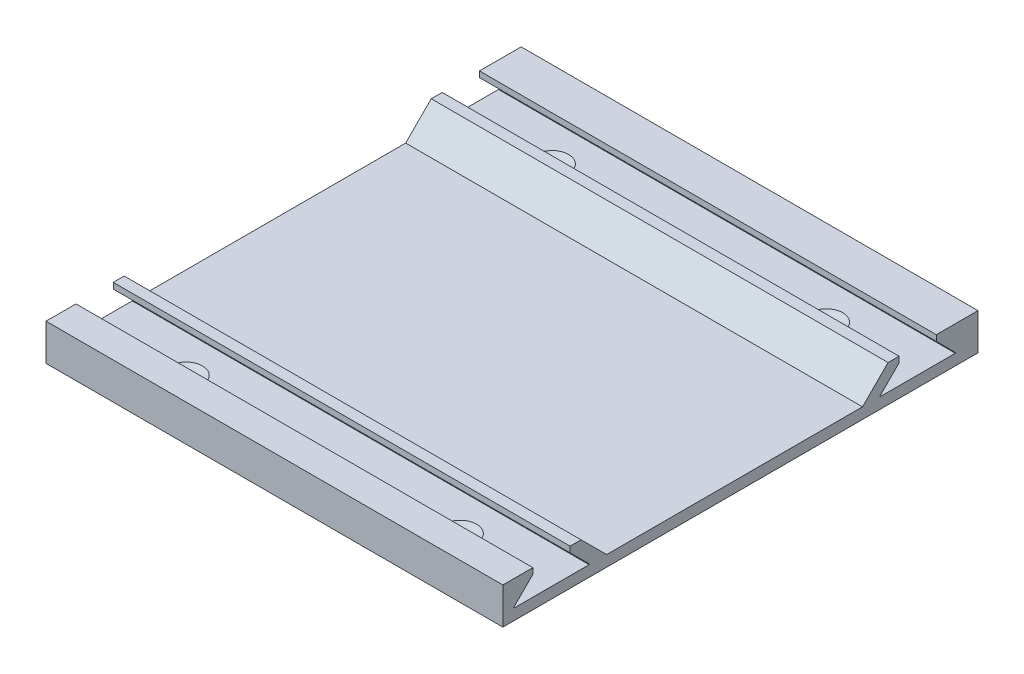
from build123d import *

# Parameters (mm, degrees)
ESQUISSE1_W             = 125
ESQUISSE1_H             = 130
BOSS_EXTRU_1_DEPTH      = 10
ENL_V_MAT_EXTRU_1_DEPTH = 125
ESQUISSE4_R             = 2.5
ENL_V_MAT_EXTRU_2_DEPTH = 3
CHANFREIN2_SIZE         = 2
ENL_V_MAT_EXTRU_6_DEPTH = 126


with BuildPart() as part:
    # Esquisse1 → Boss.-Extru.1 (new body)
    with BuildSketch(Plane(origin=(0, 0, 0), x_dir=(1, 0, 0), z_dir=(0, 1, 0))):
        with Locations((62.5, 65)):
            Rectangle(ESQUISSE1_W, ESQUISSE1_H)
    extrude(amount=BOSS_EXTRU_1_DEPTH)

    # Esquisse2 → Enlèv. mat.-Extru.1 (cut)
    with BuildSketch(Plane(origin=(125, 0, 0), x_dir=(0, 0, -1), z_dir=(1, 0, 0))):
        Polygon((8.2, 10), (8.2, 8.4), (3, 3.2), (3, 3), (23.6, 3), (23.6, 3.2), (18.4, 8.4), (18.4, 10), align=None)
        Polygon((118.6, 10), (118.6, 8.4), (123.8, 3.2), (123.8, 3), (103.2, 3), (103.2, 3.2), (108.4, 8.4), (108.4, 10), align=None)
    extrude(amount=-ENL_V_MAT_EXTRU_1_DEPTH, mode=Mode.SUBTRACT)

    # Esquisse4 → Enlèv. mat.-Extru.2 (cut)
    with BuildSketch(Plane(origin=(0, 3, 0), x_dir=(1, 0, 0), z_dir=(0, 1, 0))):
        with Locations((100, 13.3)):
            Circle(ESQUISSE4_R)
        with Locations((25, 13.3)):
            Circle(ESQUISSE4_R)
        with Locations((100, 113.5)):
            Circle(ESQUISSE4_R)
        with Locations((25, 113.5)):
            Circle(ESQUISSE4_R)
    extrude(amount=-ENL_V_MAT_EXTRU_2_DEPTH, mode=Mode.SUBTRACT)

    # Chanfrein2
    chanfrein2_edges = [part.edges().sort_by_distance(p)[0] for p in [
        (22.5, 3, -13.3),
        (97.5, 3, -113.5),
        (22.5, 3, -113.5),
        (97.5, 3, -13.3),
    ]]
    chamfer(chanfrein2_edges, length=CHANFREIN2_SIZE)

    # Esquisse8 → Enlèv. mat.-Extru.6 (cut, through all)
    with BuildSketch(Plane.ZY):
        Polygon((-105.4, 10), (-104.089482721, 8.689482721), (-98.479134235, 3.079134235), (-98.4, 3), (-28.4, 3), (-28.320865765, 3.079134235), (-22.710517279, 8.689482721), (-21.4, 10), align=None)
    extrude(amount=-ENL_V_MAT_EXTRU_6_DEPTH, mode=Mode.SUBTRACT)


solid = part.part
